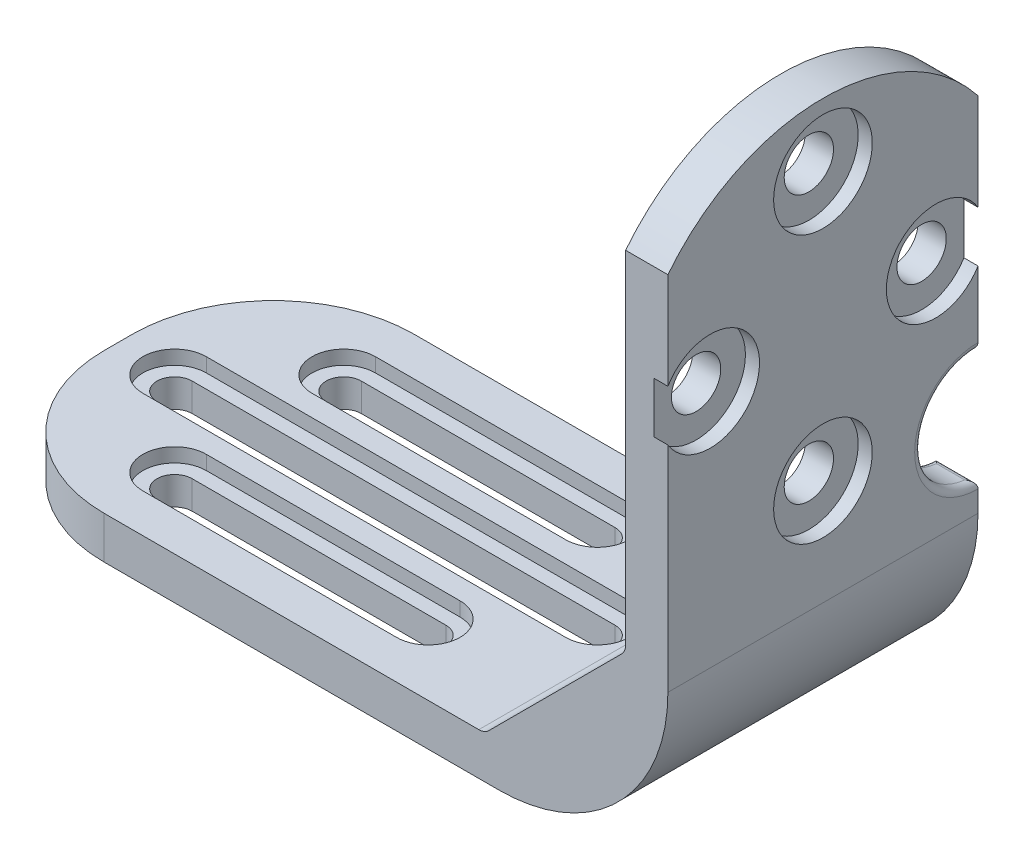
from build123d import *

# Parameters (mm, degrees)
BOSS_EXTRUDE1_DEPTH = 11
CUT_EXTRUDE1_DEPTH  = 22
CUT_EXTRUDE2_START  = 12
CUT_EXTRUDE2_DEPTH  = 1
SKETCH3_R           = 4
SKETCH3_R_2         = 1.75
CUT_EXTRUDE3_DEPTH  = 41
CUT_EXTRUDE6_START  = 31
SKETCH3_4_R         = 3.5
SKETCH3_4_R_2       = 1.75
CUT_EXTRUDE6_DEPTH  = 1
FILLET1_R           = 10
CUT_EXTRUDE7_START  = 28
SKETCH3_5_R         = 4
CUT_EXTRUDE7_DEPTH  = 1.5
FILLET2_R           = 0.5
FILLET3_R           = 1


with BuildPart() as part:
    # Sketch1 → Boss-Extrude1 (new body, symmetric)
    with BuildSketch(Plane.XY):
        with BuildLine():
            Line((-14, 12), (16, 12))
            Line((16, 12), (18, 12))
            Line((18, 12), (28, 22))
            Line((28, 22), (28, 24))
            Line((28, 24), (28, 49))
            Line((28, 49), (28, 52))
            Line((28, 52), (31, 52))
            Line((31, 52), (31, 49))
            Line((31, 49), (31, 27))
            Line((31, 27), (31, 22.757359313))
            Line((31, 22.757359313), (31, 21))
            ThreePointArc((31, 21), (27.485281374, 12.514718626), (19, 9))
            Line((19, 9), (17.242640687, 9))
            Line((17.242640687, 9), (14, 9))
            Line((14, 9), (-14, 9))
            Line((-14, 9), (-19, 9))
            Line((-19, 9), (-19, 12))
            Line((-19, 12), (-14, 12))
        make_face()
    extrude(amount=BOSS_EXTRUDE1_DEPTH, both=True)

    # Sketch2 → Cut-Extrude1 (cut)
    with BuildSketch(Plane(origin=(0, 0, 0), x_dir=(1, 0, 0), z_dir=(0, 1, 0))):
        with BuildLine():
            Line((-15, 1.25), (15, 1.25))
            ThreePointArc((15, 1.25), (16.25, 0), (15, -1.25))
            Line((15, -1.25), (-15, -1.25))
            ThreePointArc((-15, -1.25), (-16.25, 0), (-15, 1.25))
        make_face()
        with BuildLine():
            Line((-9, 7.25), (9, 7.25))
            ThreePointArc((9, 7.25), (10.25, 6), (9, 4.75))
            Line((9, 4.75), (-9, 4.75))
            ThreePointArc((-9, 4.75), (-10.25, 6), (-9, 7.25))
        make_face()
        with BuildLine():
            Line((-9, -7.25), (9, -7.25))
            ThreePointArc((9, -7.25), (10.25, -6), (9, -4.75))
            Line((9, -4.75), (-9, -4.75))
            ThreePointArc((-9, -4.75), (-10.25, -6), (-9, -7.25))
        make_face()
    extrude(amount=CUT_EXTRUDE1_DEPTH, mode=Mode.SUBTRACT)

    # Sketch2_4 → Cut-Extrude2 (cut)
    with BuildSketch(Plane(origin=(0, 0, 0), x_dir=(1, 0, 0), z_dir=(0, 1, 0)).offset(CUT_EXTRUDE2_START)):
        with BuildLine():
            Line((-9, 8.25), (9, 8.25))
            ThreePointArc((9, 8.25), (11.25, 6), (9, 3.75))
            Line((9, 3.75), (-9, 3.75))
            ThreePointArc((-9, 3.75), (-11.25, 6), (-9, 8.25))
        make_face()
        with BuildLine():
            Line((-15, 2.25), (15, 2.25))
            ThreePointArc((15, 2.25), (17.25, 0), (15, -2.25))
            Line((15, -2.25), (-15, -2.25))
            ThreePointArc((-15, -2.25), (-17.25, 0), (-15, 2.25))
        make_face()
        with BuildLine():
            Line((-9, -8.25), (9, -8.25))
            ThreePointArc((9, -8.25), (11.25, -6), (9, -3.75))
            Line((9, -3.75), (-9, -3.75))
            ThreePointArc((-9, -3.75), (-11.25, -6), (-9, -8.25))
        make_face()
    extrude(amount=-CUT_EXTRUDE2_DEPTH, mode=Mode.SUBTRACT)

    # Sketch3 → Cut-Extrude3 (cut)
    with BuildSketch(Plane(origin=(0, 0, 0), x_dir=(0, 0, -1), z_dir=(1, 0, 0))):
        with BuildLine():
            ThreePointArc((14, 38), (0, 52), (-14, 38))
            Line((-14, 38), (-18.083986214, 38))
            Line((-18.083986214, 38), (-18.083986214, 55.660635954))
            Line((-18.083986214, 55.660635954), (16.65758444, 55.660635954))
            Line((16.65758444, 55.660635954), (16.65758444, 38))
            Line((16.65758444, 38), (14, 38))
        make_face()
        with Locations((11.00722034, 26.99277966)):
            Circle(SKETCH3_R)
        with Locations(Location((-8, 38, 0), (0, 0, 180))):  # turned: the seam where the file's is
            Circle(SKETCH3_R_2)
        with Locations(Location((0, 28.5, 0), (0, 0, 180))):  # turned: the seam where the file's is
            Circle(SKETCH3_R_2)
        with Locations(Location((8, 38, 0), (0, 0, 180))):  # turned: the seam where the file's is
            Circle(SKETCH3_R_2)
        with Locations(Location((0, 47.5, 0), (0, 0, 180))):  # turned: the seam where the file's is
            Circle(SKETCH3_R_2)
    extrude(amount=CUT_EXTRUDE3_DEPTH, mode=Mode.SUBTRACT)

    # Sketch3_4 → Cut-Extrude6 (cut)
    with BuildSketch(Plane(origin=(0, 0, 0), x_dir=(0, 0, -1), z_dir=(1, 0, 0)).offset(CUT_EXTRUDE6_START)):
        with Locations(Location((0, 28.5, 0), (0, 0, 180))):  # turned: the seam where the file's is
            Circle(SKETCH3_4_R)
        with Locations(Location((0, 28.5, 0), (0, 0, 180))):  # turned: the seam where the file's is
            Circle(SKETCH3_4_R_2, mode=Mode.SUBTRACT)
        with Locations((-8, 38)):
            Circle(SKETCH3_4_R)
        with Locations(Location((-8, 38, 0), (0, 0, 180))):  # turned: the seam where the file's is
            Circle(SKETCH3_4_R_2, mode=Mode.SUBTRACT)
        with Locations(Location((0, 47.5, 0), (0, 0, 180))):  # turned: the seam where the file's is
            Circle(SKETCH3_4_R)
        with Locations(Location((0, 47.5, 0), (0, 0, 180))):  # turned: the seam where the file's is
            Circle(SKETCH3_4_R_2, mode=Mode.SUBTRACT)
        with Locations((8, 38)):
            Circle(SKETCH3_4_R)
        with Locations(Location((8, 38, 0), (0, 0, 180))):  # turned: the seam where the file's is
            Circle(SKETCH3_4_R_2, mode=Mode.SUBTRACT)
    extrude(amount=-CUT_EXTRUDE6_DEPTH, mode=Mode.SUBTRACT)

    # Fillet1
    fillet1_edges = [part.edges().sort_by_distance(p)[0] for p in [
        (-19, 10.5, -11),
        (-19, 10.5, 11),
    ]]
    fillet(fillet1_edges, radius=FILLET1_R)

    # Sketch3_5 → Cut-Extrude7 (cut)
    with BuildSketch(Plane(origin=(0, 0, 0), x_dir=(0, 0, -1), z_dir=(1, 0, 0)).offset(CUT_EXTRUDE7_START)):
        with Locations((0, 38)):
            Circle(SKETCH3_5_R)
    extrude(amount=CUT_EXTRUDE7_DEPTH, mode=Mode.SUBTRACT)

    # Fillet2
    fillet2_edges = [part.edges().sort_by_distance(p)[0] for p in [
        (29.5, 22.992786177, -11),
        (29.5, 30.992773143, -11),
        (28, 26.99277966, -7.00722034),
        (31, 26.99277966, -7.00722034),
        (28, 38, 4),
    ]]
    fillet(fillet2_edges, radius=FILLET2_R)

    # Fillet3
    fillet3_edges = [part.edges().sort_by_distance(p)[0] for p in [
        (18, 12, 0),
        (28, 22, 0),
    ]]
    fillet(fillet3_edges, radius=FILLET3_R)


solid = part.part
